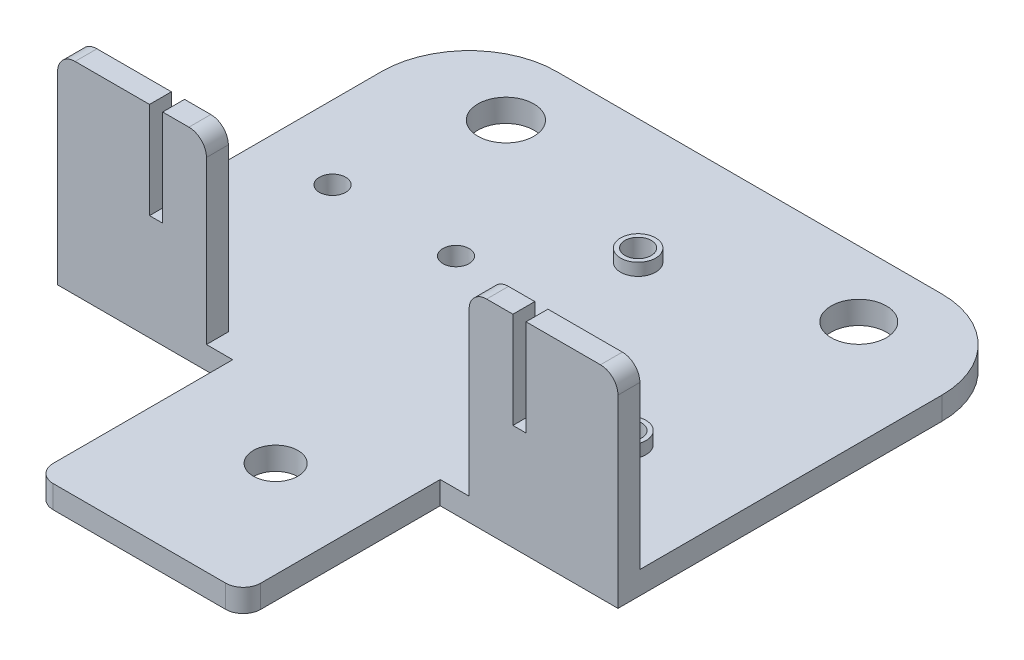
from build123d import *

# Parameters (mm, degrees)
MAIN_BODY_DEPTH          = 2.6
SKETCH4_W                = 17
SKETCH4_H                = 2.5
FLANGES_DEPTH            = 20.5
SKETCH5_R                = 2
DRILL_HOLD_EXTRUDE_DEPTH = 1.4
SKETCH2_R                = 3.2
SKETCH2_R_2              = 3.15
SKETCH2_R_3              = 1.5
SKETCH2_R_4              = 2.55
SCREW_HOLES_DEPTH        = 21.5
SCREW_HOLES_DEPTH_BACK   = 3.6
FLANGE_FILLET_R          = 2
SKETCH6_W                = 1.5
SKETCH6_H                = 11
FLANGE_NOTCHES_DEPTH     = 26
MAIN_LOWER_BODY_FILLET_R = 2


with BuildPart() as part:
    # Sketch1 → Main Body (new body)
    with BuildSketch(Plane(origin=(0, 0, 0), x_dir=(1, 0, 0), z_dir=(0, 1, 0))):
        with BuildLine():
            Line((11.7, -23.5), (32, -23.5))
            Line((32, -23.5), (32, 13.5))
            ThreePointArc((32, 13.5), (29.071067812, 20.571067812), (22, 23.5))
            Line((22, 23.5), (-22, 23.5))
            ThreePointArc((-22, 23.5), (-29.071067812, 20.571067812), (-32, 13.5))
            Line((-32, 13.5), (-32, -23.5))
            Line((-32, -23.5), (-12, -23.5))
            Line((-12, -23.5), (-12, -46))
            Line((-12, -46), (11.7, -46))
            Line((11.7, -46), (11.7, -23.5))
        make_face()
    extrude(amount=MAIN_BODY_DEPTH)

    # Sketch4 → Flanges (add)
    with BuildSketch(Plane(origin=(0, 2.6, 0), x_dir=(1, 0, 0), z_dir=(0, 1, 0))):
        with Locations((-23.5, -22.25)):
            Rectangle(SKETCH4_W, SKETCH4_H)
        with Locations((23.5, -22.25)):
            Rectangle(SKETCH4_W, SKETCH4_H)
    extrude(amount=FLANGES_DEPTH)

    # Sketch5 → Drill hold extrude (add)
    with BuildSketch(Plane(origin=(0, 2.6, 0), x_dir=(1, 0, 0), z_dir=(0, 1, 0))):
        with Locations((19, -9.3)):
            Circle(SKETCH5_R)
        with Locations((1.5, 9.3)):
            Circle(SKETCH5_R)
    extrude(amount=DRILL_HOLD_EXTRUDE_DEPTH)

    # Sketch2 → Screw holes (cut, two sides)
    with BuildSketch(Plane(origin=(0, 2.6, 0), x_dir=(1, 0, 0), z_dir=(0, 1, 0))) as screw_holes_sk:
        with Locations((-20.1, 15.8)):
            Circle(SKETCH2_R)
        with Locations((20, 16)):
            Circle(SKETCH2_R_2)
        with Locations((1.5, 9.3)):
            Circle(SKETCH2_R_3)
        with Locations((-23.6, -0.5)):
            Circle(SKETCH2_R_3)
        with Locations((-9.5, -0.5)):
            Circle(SKETCH2_R_3)
        with Locations((19, -9.3)):
            Circle(SKETCH2_R_3)
        with Locations((0.7, -31.3)):
            Circle(SKETCH2_R_4)
    extrude(amount=SCREW_HOLES_DEPTH, mode=Mode.SUBTRACT)
    extrude(screw_holes_sk.sketch, amount=-SCREW_HOLES_DEPTH_BACK, mode=Mode.SUBTRACT)

    # Flange Fillet
    flange_fillet_edges = [part.edges().sort_by_distance(p)[0] for p in [
        (-32, 23.1, 22.25),
        (-15, 23.1, 22.25),
        (32, 23.1, 22.25),
        (15, 23.1, 22.25),
    ]]
    fillet(flange_fillet_edges, radius=FLANGE_FILLET_R)

    # Sketch6 → Flange Notches (cut, through all)
    with BuildSketch(Plane(origin=(0, 0, 21), x_dir=(-1, 0, 0), z_dir=(0, 0, -1))):
        with Locations((-20.75, 17.6)):
            Rectangle(SKETCH6_W, SKETCH6_H)
        with Locations((20.75, 17.6)):
            Rectangle(SKETCH6_W, SKETCH6_H)
    extrude(amount=-FLANGE_NOTCHES_DEPTH, mode=Mode.SUBTRACT)

    # Main lower body Fillet
    main_lower_body_fillet_edges = [part.edges().sort_by_distance(p)[0] for p in [
        (11.7, 1.3, 46),
        (-12, 1.3, 46),
    ]]
    fillet(main_lower_body_fillet_edges, radius=MAIN_LOWER_BODY_FILLET_R)


solid = part.part
